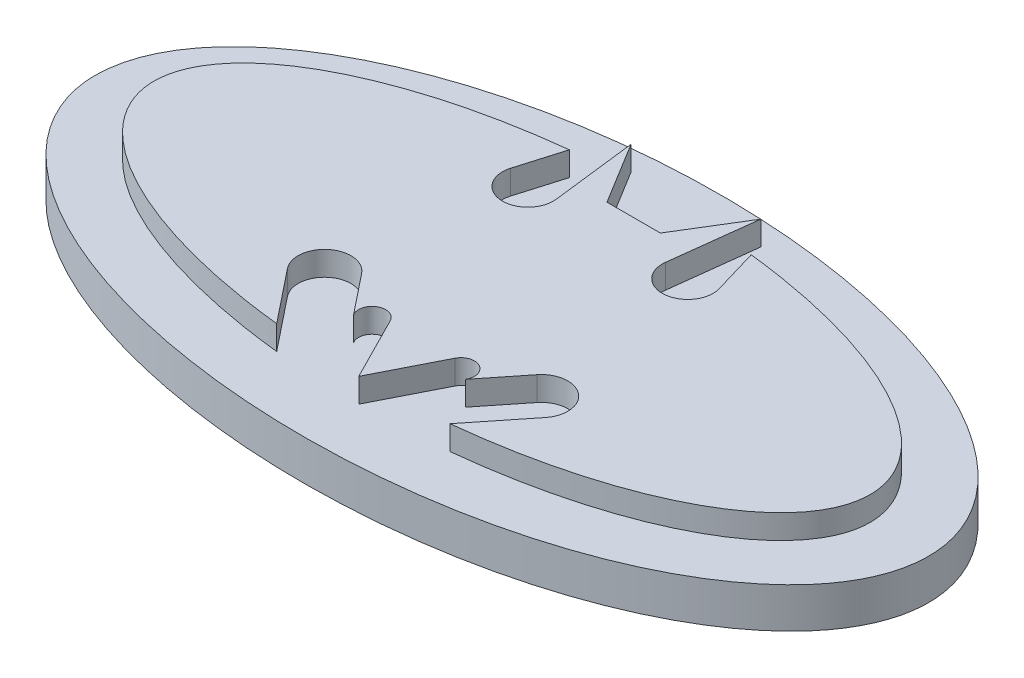
from build123d import *

# Parameters (mm, degrees)
BOSS_EXTRUDE1_DEPTH = 3
SKETCH3_RX          = 51.78738506
SKETCH3_RY          = 25.979876283
BOSS_EXTRUDE2_DEPTH = 5


with BuildPart() as part:
    # Sketch1 → Boss-Extrude1 (new body)
    with BuildSketch(Plane(origin=(0, 0, 0), x_dir=(1, 0, 0), z_dir=(0, 1, 0))):
        with BuildLine():
            Line((-3.321687117, 15.122078178), (3.321687117, 15.122078178))
            Line((3.321687117, 15.122078178), (8.06490939, 22.861019782))
            Line((8.06490939, 22.861019782), (6.79057501, 12.282705553))
            ThreePointArc((6.79057501, 12.282705553), (10.195399196, 8.752014841), (12.965183657, 12.800088295))
            Line((12.965183657, 12.800088295), (11.304410068, 18.42528916))
            add(Edge.make_bspline(
                [(10.770897783, -18.483723052), (44.301388319, -14.905656622), (44.515143314, -0.117832697), (44.72889831, 14.669991228), (11.304410068, 18.42528916)],
                knots=[1.81517724, 1.81517724, 1.81517724, 3.135407087, 3.135407087, 4.455636934, 4.455636934, 4.455636934], degree=2, weights=[1, 0.789921765, 1, 0.789921765, 1]))
            Line((10.770897783, -18.483723052), (16.042361236, -11.874619993))
            ThreePointArc((16.042361236, -11.874619993), (15.523130653, -7.262949217), (10.911459877, -7.7821798))
            Line((10.911459877, -7.7821798), (6.951304014, -12.747229536))
            ThreePointArc((6.951304014, -12.747229536), (6.336406018, -10.410642529), (4.025576443, -11.116195545))
            Line((4.025576443, -11.116195545), (0, -19.049742282))
            Line((0, -19.049742282), (-4.025576443, -11.116195545))
            ThreePointArc((-4.025576443, -11.116195545), (-6.336406018, -10.410642529), (-6.951304014, -12.747229536))
            Line((-6.951304014, -12.747229536), (-10.911459877, -7.7821798))
            ThreePointArc((-10.911459877, -7.7821798), (-15.523130653, -7.262949217), (-16.042361236, -11.874619993))
            Line((-16.042361236, -11.874619993), (-10.770897783, -18.483723052))
            add(Edge.make_bspline(
                [(-11.304410068, 18.42528916), (-44.72889831, 14.669991228), (-44.515143314, -0.117832697), (-44.301388319, -14.905656622), (-10.770897783, -18.483723052)],
                knots=[1.827548373, 1.827548373, 1.827548373, 3.14777822, 3.14777822, 4.468008067, 4.468008067, 4.468008067], degree=2, weights=[1, 0.789921765, 1, 0.789921765, 1]))
            Line((-11.304410068, 18.42528916), (-12.965183657, 12.800088295))
            ThreePointArc((-12.965183657, 12.800088295), (-10.195399196, 8.752014841), (-6.79057501, 12.282705553))
            Line((-6.79057501, 12.282705553), (-8.06490939, 22.861019782))
            Line((-8.06490939, 22.861019782), (-3.321687117, 15.122078178))
        make_face()
    extrude(amount=BOSS_EXTRUDE1_DEPTH)

    # Sketch3 → Boss-Extrude2 (add)
    with BuildSketch(Plane.XZ):
        with Locations(Location((0, 0), (0, 0, 180))):
            Ellipse(SKETCH3_RX, SKETCH3_RY)
    extrude(amount=BOSS_EXTRUDE2_DEPTH)


solid = part.part
